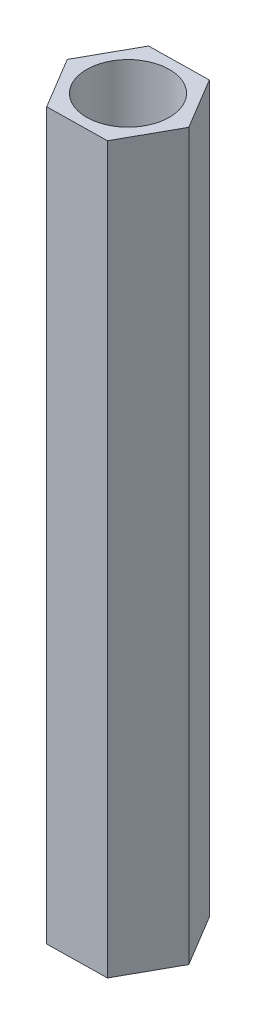
from build123d import *

# Parameters (mm, degrees)
SKETCH_1_R      = 2
EXTRUDE_1_DEPTH = 35


with BuildPart() as part:
    # 草图1 → 凸台-拉伸1 (new body)
    with BuildSketch(Plane(origin=(0, 0, 0), x_dir=(1, 0, 0), z_dir=(0, 1, 0))):
        Polygon((1.401930385, 2.523474693), (-1.484427998, 2.475844675), (-2.886358383, -0.047630019), (-1.401930385, -2.523474693), (1.484427998, -2.475844675), (2.886358383, 0.047630019), align=None)
        Circle(SKETCH_1_R, mode=Mode.SUBTRACT)
    extrude(amount=EXTRUDE_1_DEPTH)


solid = part.part
